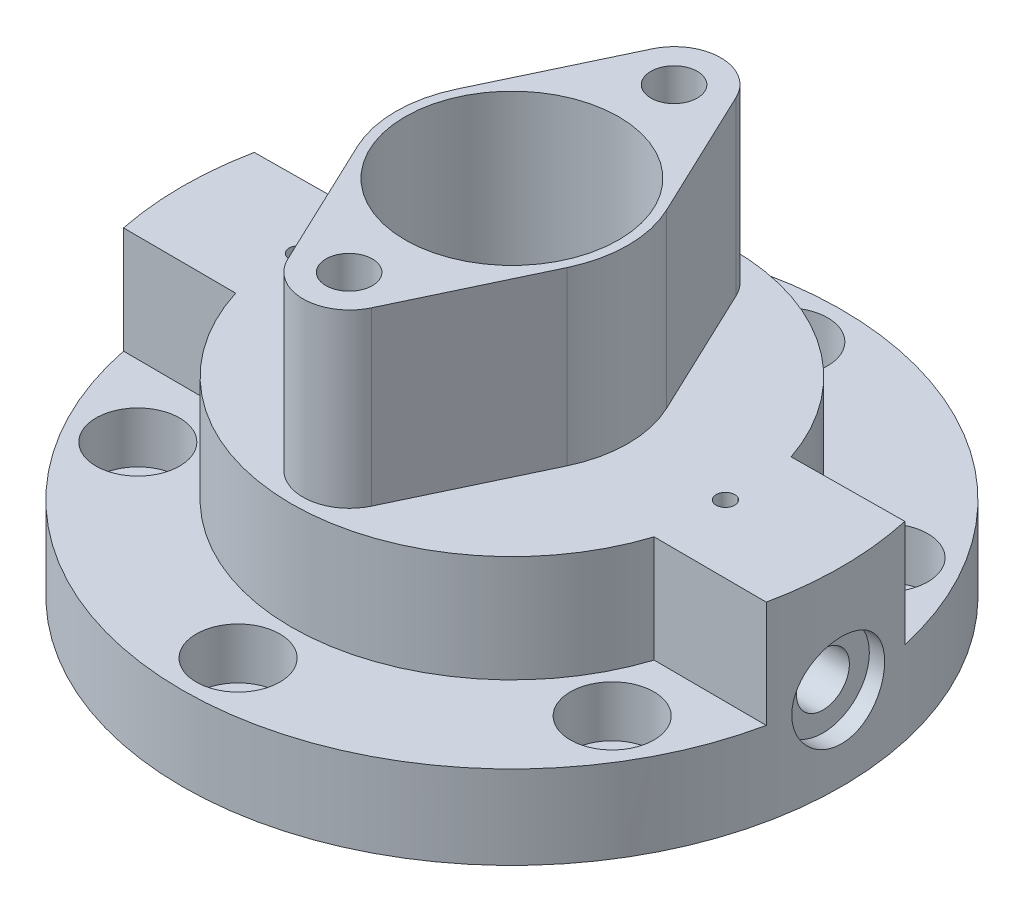
from build123d import *

# Parameters (mm, degrees)
SKETCH1_R           = 35.5
BOSS_EXTRUDE1_DEPTH = 9
BOSS_EXTRUDE2_START = 11.5
BOSS_EXTRUDE2_DEPTH = 11.5
BOSS_EXTRUDE3_DEPTH = 18.5
SKETCH3_R           = 2.5
CUT_EXTRUDE1_DEPTH  = 7.5
SKETCH4_R           = 2.75
CUT_EXTRUDE2_DEPTH  = 59.485040822
SKETCH4_3_R         = 4.5
SKETCH4_3_R_2       = 2.75
CUT_EXTRUDE3_DEPTH  = 5.5
CIRPATTERN1_COUNT   = 6
SKETCH5_R           = 5
SKETCH5_R_2         = 2.85
CUT_EXTRUDE4_DEPTH  = 2
SKETCH5_2_R         = 2.85
CUT_EXTRUDE5_DEPTH  = 15
SKETCH6_R           = 1
CUT_EXTRUDE6_DEPTH  = 12


with BuildPart() as part:
    # Sketch1 → Boss-Extrude1 (new body)
    with BuildSketch(Plane(origin=(0, 0, 0), x_dir=(1, 0, 0), z_dir=(0, 1, 0))):
        Circle(SKETCH1_R)
    extrude(amount=-BOSS_EXTRUDE1_DEPTH)

    # Sketch1_3 → Boss-Extrude2 (add)
    with BuildSketch(Plane(origin=(0, 0, 0), x_dir=(1, 0, 0), z_dir=(0, 1, 0)).offset(BOSS_EXTRUDE2_START)):
        with BuildLine():
            Line((34.663332794, 7.661811773), (22.516948444, 7.553114112))
            ThreePointArc((22.516948444, 7.553114112), (-0.21252959, 23.749049058), (-22.64851663, 7.148929601))
            Line((-22.64851663, 7.148929601), (-34.79490098, 7.04023194))
            ThreePointArc((-34.79490098, 7.04023194), (-35.5, 0), (-34.79490098, -7.04023194))
            Line((-34.79490098, -7.04023194), (-22.6663516, -7.092179155))
            ThreePointArc((-22.6663516, -7.092179155), (-0.101721567, -23.749782162), (22.604768769, -7.286077746))
            Line((22.604768769, -7.286077746), (34.733318149, -7.338024961))
            ThreePointArc((34.733318149, -7.338024961), (35.307809294, -3.688983986), (35.5, 0))
            ThreePointArc((35.5, 0), (35.290213333, 3.85367914), (34.663332794, 7.661811773))
        make_face()
    extrude(amount=-BOSS_EXTRUDE2_DEPTH)

    # Sketch2 → Boss-Extrude3 (add)
    with BuildSketch(Plane(origin=(0, 11.5, 0), x_dir=(1, 0, 0), z_dir=(0, 1, 0))):
        with BuildLine():
            Line((-4.517539515, 19.642857143), (-11.293848786, 5.357142857))
            ThreePointArc((-11.293848786, 5.357142857), (-12.5, 0), (-11.293848786, -5.357142857))
            Line((-11.293848786, -5.357142857), (-4.517539515, -19.642857143))
            ThreePointArc((-4.517539515, -19.642857143), (0, -22.5), (4.517539515, -19.642857143))
            Line((4.517539515, -19.642857143), (11.293848786, -5.357142857))
            ThreePointArc((11.293848786, -5.357142857), (12.5, 0), (11.293848786, 5.357142857))
            Line((11.293848786, 5.357142857), (4.517539515, 19.642857143))
            ThreePointArc((4.517539515, 19.642857143), (0, 22.5), (-4.517539515, 19.642857143))
        make_face()
    extrude(amount=BOSS_EXTRUDE3_DEPTH)

    # Sketch3 → Cut-Extrude1 (cut)
    with BuildSketch(Plane(origin=(0, 30, 0), x_dir=(1, 0, 0), z_dir=(0, 1, 0))):
        with Locations((0, 17.465877309)):
            Circle(SKETCH3_R)
        with Locations((0, -17.534122691)):
            Circle(SKETCH3_R)
    extrude(amount=-CUT_EXTRUDE1_DEPTH, mode=Mode.SUBTRACT)

    # Sketch4 → Cut-Extrude2 (cut, through all)
    with BuildSketch(Plane(origin=(0, 0, 0), x_dir=(1, 0, 0), z_dir=(0, 1, 0))):
        with Locations((0, 29.5)):
            Circle(SKETCH4_R)
    cut_extrude2 = extrude(amount=-CUT_EXTRUDE2_DEPTH, mode=Mode.SUBTRACT)

    # Sketch4_3 → Cut-Extrude3 (cut)
    with BuildSketch(Plane(origin=(0, 0, 0), x_dir=(1, 0, 0), z_dir=(0, 1, 0))):
        with Locations((0, 29.5)):
            Circle(SKETCH4_3_R)
        with Locations((0, 29.5)):
            Circle(SKETCH4_3_R_2, mode=Mode.SUBTRACT)
    cut_extrude3 = extrude(amount=-CUT_EXTRUDE3_DEPTH, mode=Mode.SUBTRACT)

    # CirPattern1: Cut-Extrude2, Cut-Extrude3 ×6 about axis
    cirpattern1_axis = Axis((0, 11.5, 0), (0, 1, 0))
    add([cut_extrude2.rotate(cirpattern1_axis, i * 360 / CIRPATTERN1_COUNT) for i in range(1, CIRPATTERN1_COUNT)], mode=Mode.SUBTRACT)
    add([cut_extrude3.rotate(cirpattern1_axis, i * 360 / CIRPATTERN1_COUNT) for i in range(1, CIRPATTERN1_COUNT)], mode=Mode.SUBTRACT)

    # Sketch5 → Cut-Extrude4 (cut)
    with BuildSketch(Plane(origin=(35.5, 0, 0), x_dir=(0, 0, -1), z_dir=(1, 0, 0))):
        Circle(SKETCH5_R)
        Circle(SKETCH5_R_2, mode=Mode.SUBTRACT)
    cut_extrude4 = extrude(amount=-CUT_EXTRUDE4_DEPTH, mode=Mode.SUBTRACT)

    # Sketch5_2 → Cut-Extrude5 (cut)
    with BuildSketch(Plane(origin=(35.5, 0, 0), x_dir=(0, 0, -1), z_dir=(1, 0, 0))):
        Circle(SKETCH5_2_R)
    cut_extrude5 = extrude(amount=-CUT_EXTRUDE5_DEPTH, mode=Mode.SUBTRACT)

    # Mirror1: Cut-Extrude4, Cut-Extrude5 across plane
    add(cut_extrude4.mirror(Plane(origin=(0, 0, 0), x_dir=(0, 0, 1), z_dir=(1, 0, 0))), mode=Mode.SUBTRACT)
    add(cut_extrude5.mirror(Plane(origin=(0, 0, 0), x_dir=(0, 0, 1), z_dir=(1, 0, 0))), mode=Mode.SUBTRACT)

    # Sketch6 → Cut-Extrude6 (cut)
    with BuildSketch(Plane(origin=(0, 11.5, 0), x_dir=(1, 0, 0), z_dir=(0, 1, 0))):
        with Locations((23, 0)):
            Circle(SKETCH6_R)
    cut_extrude6 = extrude(amount=-CUT_EXTRUDE6_DEPTH, mode=Mode.SUBTRACT)

    # Mirror2: Cut-Extrude6 across plane
    add(cut_extrude6.mirror(Plane(origin=(0, 0, 0), x_dir=(0, 0, 1), z_dir=(1, 0, 0))), mode=Mode.SUBTRACT)

    # Sketch7 → Cut-Revolve1 (revolve, cut)
    with BuildSketch(Plane(origin=(0, 0, 0), x_dir=(0, 0, -1), z_dir=(1, 0, 0))):
        Polygon((0, 30), (0, -9), (-15.5, -9), (-15.5, 0), (-13.133679217, 0), (-10.942230479, 8.17859803), (-7.332376652, 8.17859803), (-7.332376652, 11.5), (-11.5, 11.5), (-11.5, 30), align=None)
    revolve(axis=Axis((0, 30, 0), (0, -1, 0)), mode=Mode.SUBTRACT)


solid = part.part
